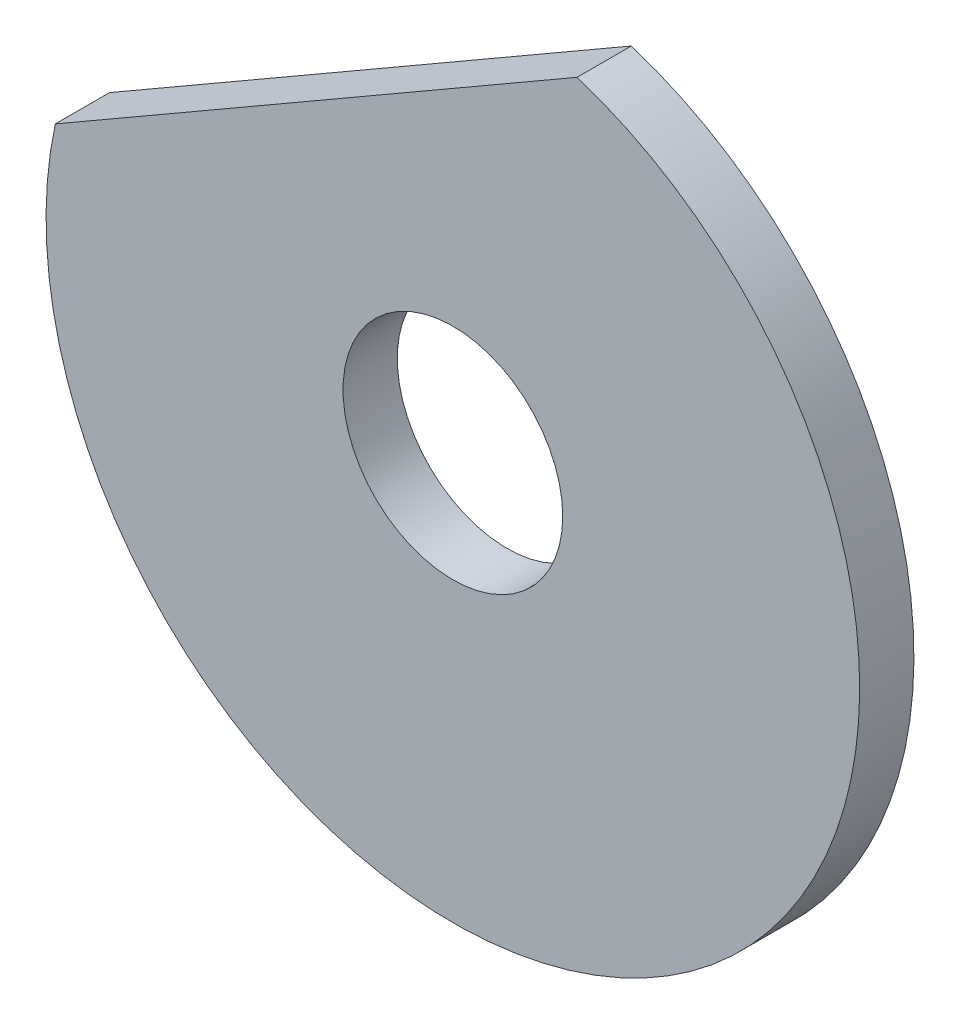
from build123d import *

# Parameters (mm, degrees)
SZKIC1_R                    = 4.05
DODANIE_WYCI_GNI_CIE1_DEPTH = 2


with BuildPart() as part:
    # Szkic1 → Dodanie-wyciągnięcie1 (new body)
    with BuildSketch(Plane.XY):
        with BuildLine():
            Line((-14.659537999, 3.17772649), (4.577777133, 14.28439556))
            ThreePointArc((4.577777133, 14.28439556), (7.5, -12.990381057), (-14.659537999, 3.17772649))
        make_face()
        Circle(SZKIC1_R, mode=Mode.SUBTRACT)
    extrude(amount=DODANIE_WYCI_GNI_CIE1_DEPTH)


solid = part.part
